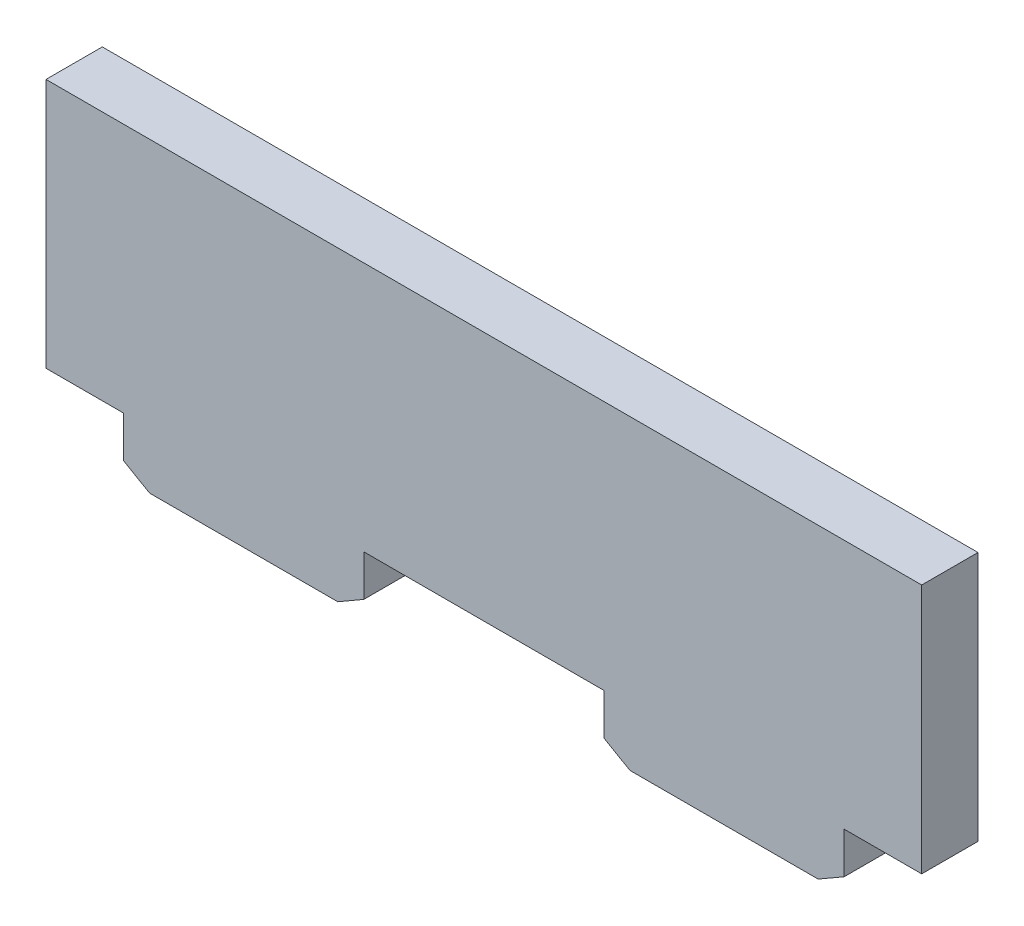
from build123d import *

# Parameters (mm, degrees)
SKETCH1_W             = 44.45
SKETCH1_H             = 12.7
BOSS_EXTRUDE1_DEPTH   = 2.8575
SKETCH2_W             = 12.192
SKETCH2_H             = 2.8575
BOSS_EXTRUDE2_DEPTH   = 2.8575
CHAMFER1_SIZE         = 0.762
CHAMFER1_SIZE2        = 1.319822715
CHAMFER1_PART_2_SIZE  = 0.762
CHAMFER1_PART_2_SIZE2 = 1.319822715
CHAMFER2_SIZE         = 0.762
CHAMFER2_SIZE2        = 1.319822715
CHAMFER2_PART_2_SIZE  = 0.762
CHAMFER2_PART_2_SIZE2 = 1.319822715


with BuildPart() as part:
    # Sketch1 → Boss-Extrude1 (new body)
    with BuildSketch(Plane.XY):
        Rectangle(SKETCH1_W, SKETCH1_H)
    extrude(amount=BOSS_EXTRUDE1_DEPTH)

    # Sketch2 → Boss-Extrude2 (add)
    with BuildSketch(Plane(origin=(0, -6.35, 0), x_dir=(-1, 0, 0), z_dir=(0, -1, 0))):
        with Locations((12.192, -1.42875)):
            Rectangle(SKETCH2_W, SKETCH2_H)
        with Locations((-12.192, -1.42875)):
            Rectangle(SKETCH2_W, SKETCH2_H)
    extrude(amount=BOSS_EXTRUDE2_DEPTH)

    # Chamfer1
    chamfer1_edges = [part.edges().sort_by_distance(p)[0] for p in [
        (-18.288, -9.2075, 1.42875),
    ]]
    chamfer1_side = [part.faces().sort_by_distance(p)[0] for p in [
        (-18.288, -7.77875, 1.42875),
    ]]
    chamfer(chamfer1_edges, length=CHAMFER1_SIZE, length2=CHAMFER1_SIZE2, reference=chamfer1_side[0])

    # Chamfer1 part 2
    chamfer1_part_2_edges = [part.edges().sort_by_distance(p)[0] for p in [
        (6.096, -9.2075, 1.42875),
    ]]
    chamfer1_part_2_side = [part.faces().sort_by_distance(p)[0] for p in [
        (6.096, -7.77875, 1.42875),
    ]]
    chamfer(chamfer1_part_2_edges, length=CHAMFER1_PART_2_SIZE, length2=CHAMFER1_PART_2_SIZE2, reference=chamfer1_part_2_side[0])

    # Chamfer2
    chamfer2_edges = [part.edges().sort_by_distance(p)[0] for p in [
        (-6.096, -9.2075, 1.42875),
    ]]
    chamfer2_side = [part.faces().sort_by_distance(p)[0] for p in [
        (-6.096, -7.77875, 1.42875),
    ]]
    chamfer(chamfer2_edges, length=CHAMFER2_SIZE, length2=CHAMFER2_SIZE2, reference=chamfer2_side[0])

    # Chamfer2 part 2
    chamfer2_part_2_edges = [part.edges().sort_by_distance(p)[0] for p in [
        (18.288, -9.2075, 1.42875),
    ]]
    chamfer2_part_2_side = [part.faces().sort_by_distance(p)[0] for p in [
        (18.288, -7.77875, 1.42875),
    ]]
    chamfer(chamfer2_part_2_edges, length=CHAMFER2_PART_2_SIZE, length2=CHAMFER2_PART_2_SIZE2, reference=chamfer2_part_2_side[0])


solid = part.part
